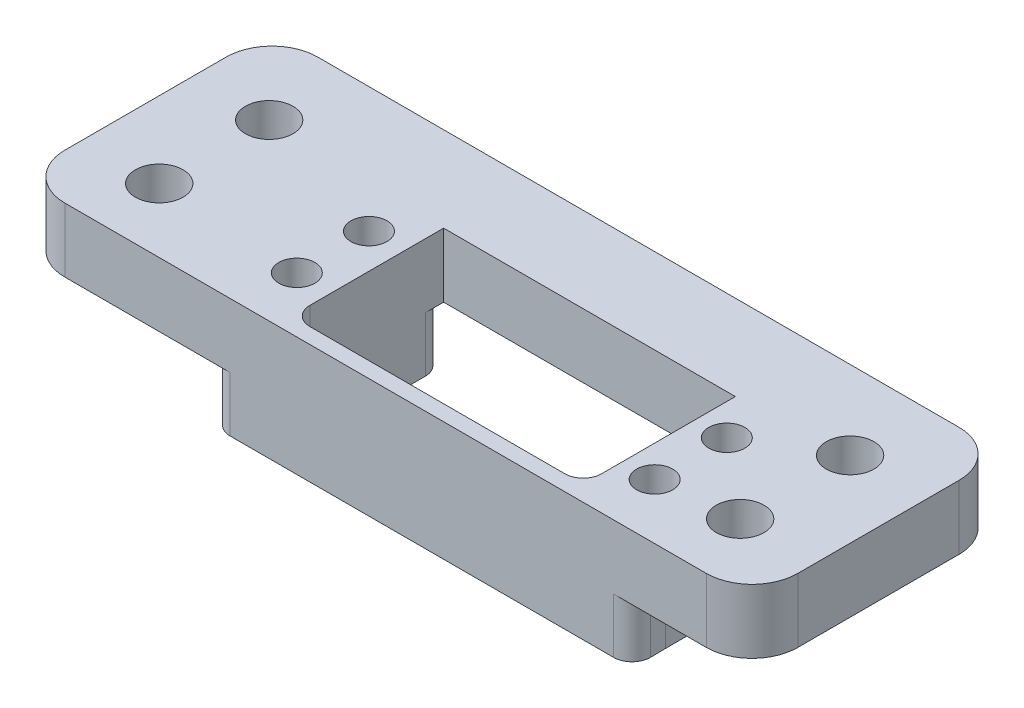
from build123d import *

# Parameters (mm, degrees)
SKETCH1_W             = 101.6
SKETCH1_H             = 35.052
INITIAL_EXTRUDE_DEPTH = 8.89
SKETCH2_R             = 3.302
SCREW_HOLES_DEPTH     = 9.89
SKETCH4_R             = 2.5
SKETCH4_W             = 40.432286119
SKETCH4_H             = 21.082
SERVO_HOLE_DEPTH      = 9.89
FILLET1_R             = 6.35
SKETCH6_R             = 5.715
SCREW_HEAD_HOLE_DEPTH = 3.81
SKETCH7_W             = 8.89
SKETCH7_H             = 21.082
SKETCH7_R             = 2.55
BOSS_EXTRUDE1_DEPTH   = 7.62
FILLET2_R             = 2.54
BOSS_EXTRUDE2_DEPTH   = 7.62
FILLET3_R             = 2.54


with BuildPart() as part:
    # Sketch1 → Initial Extrude (new body)
    with BuildSketch(Plane(origin=(0, 0, 0), x_dir=(1, 0, 0), z_dir=(0, 1, 0))):
        with Locations((50.8, 17.526)):
            Rectangle(SKETCH1_W, SKETCH1_H)
    extrude(amount=INITIAL_EXTRUDE_DEPTH)

    # Sketch2 → Screw Holes (cut, through all)
    with BuildSketch(Plane(origin=(0, 8.89, 0), x_dir=(1, 0, 0), z_dir=(0, 1, 0))):
        with Locations((10.541, 8.89)):
            Circle(SKETCH2_R)
        with Locations((91.059, 24.13)):
            Circle(SKETCH2_R)
        with Locations((10.541, 24.13)):
            Circle(SKETCH2_R)
        with Locations((91.059, 8.89)):
            Circle(SKETCH2_R)
    extrude(amount=-SCREW_HOLES_DEPTH, mode=Mode.SUBTRACT)

    # Sketch4 → Servo Hole (cut, through all)
    with BuildSketch(Plane(origin=(0, 8.89, 0), x_dir=(1, 0, 0), z_dir=(0, 1, 0))):
        with Locations((30.8, 7.7)):
            Circle(SKETCH4_R)
        with Locations((30.8, 17.7)):
            Circle(SKETCH4_R)
        with Locations((55.824856941, 12.7)):
            Rectangle(SKETCH4_W, SKETCH4_H)
        with Locations((80.4, 17.7)):
            Circle(SKETCH4_R)
        with Locations((80.4, 7.7)):
            Circle(SKETCH4_R)
    extrude(amount=-SERVO_HOLE_DEPTH, mode=Mode.SUBTRACT)

    # Fillet1
    fillet1_edges = [part.edges().sort_by_distance(p)[0] for p in [
        (0, 4.445, 0),
        (0, 4.445, -35.052),
        (101.6, 4.445, -35.052),
        (101.6, 4.445, 0),
    ]]
    fillet(fillet1_edges, radius=FILLET1_R)

    # Sketch6 → Screw Head Hole (cut)
    with BuildSketch(Plane(origin=(0, 0, 0), x_dir=(-1, 0, 0), z_dir=(0, -1, 0))):
        with Locations((-10.541, 8.89)):
            Circle(SKETCH6_R)
        with Locations((-10.541, 24.13)):
            Circle(SKETCH6_R)
        with Locations((-91.059, 24.13)):
            Circle(SKETCH6_R)
        with Locations((-91.059, 8.89)):
            Circle(SKETCH6_R)
    extrude(amount=-SCREW_HEAD_HOLE_DEPTH, mode=Mode.SUBTRACT)

    # Sketch7 → Boss-Extrude1 (add)
    with BuildSketch(Plane.XZ):
        with Locations((31.163713881, -12.7)):
            Rectangle(SKETCH7_W, SKETCH7_H)
        with Locations((30.8, -7.7)):
            Circle(SKETCH7_R, mode=Mode.SUBTRACT)
        with Locations((30.8, -17.7)):
            Circle(SKETCH7_R, mode=Mode.SUBTRACT)
        with Locations((80.486, -12.7)):
            Rectangle(SKETCH7_W, SKETCH7_H)
        with Locations((80.4, -7.7)):
            Circle(SKETCH7_R, mode=Mode.SUBTRACT)
        with Locations((80.4, -17.7)):
            Circle(SKETCH7_R, mode=Mode.SUBTRACT)
    extrude(amount=BOSS_EXTRUDE1_DEPTH)

    # Fillet2
    fillet2_edges = [part.edges().sort_by_distance(p)[0] for p in [
        (35.608713881, -3.81, -23.241),
        (35.608713881, -3.81, -2.159),
        (26.718713881, -3.81, -2.159),
        (26.718713881, -3.81, -23.241),
        (76.041, -3.81, -2.159),
        (76.041, -3.81, -23.241),
        (84.931, -3.81, -23.241),
        (84.931, -3.81, -2.159),
    ]]
    fillet(fillet2_edges, radius=FILLET2_R)

    # Sketch8 → Boss-Extrude2 (add)
    with BuildSketch(Plane.XZ):
        Polygon((26.718713881, -4.699), (26.718713881, 0), (84.997322511, 0), (84.931, -4.699), (76.041, -4.699), (76.041, -2.159), (35.608713881, -2.159), (35.608713881, -4.699), align=None)
    extrude(amount=BOSS_EXTRUDE2_DEPTH)

    # Fillet3
    fillet3_edges = [part.edges().sort_by_distance(p)[0] for p in [
        (26.718713881, -3.81, 0),
        (84.997322511, -3.81, 0),
        (76.041, 0.635, -2.159),
        (35.608713881, 0.635, -2.159),
    ]]
    fillet(fillet3_edges, radius=FILLET3_R)


solid = part.part
